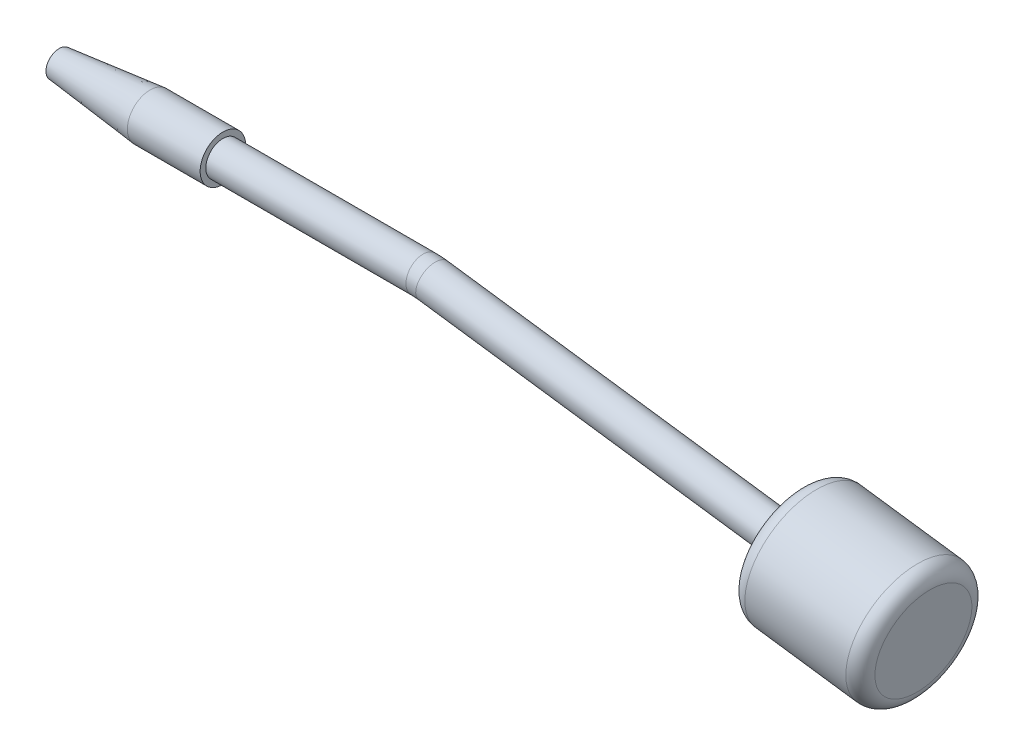
from build123d import *

# Parameters (mm, degrees)
SWEEP1_PROFILE_R = 2.9845
FILLET1_R        = 2.54


with BuildPart() as part:
    # Sketch1 → Revolve1 (revolve)
    with BuildSketch(Plane.XY):
        Polygon((-63.5, -0.79375), (-63.5, -2.286), (-47.625, -3.96875), (-34.925, -3.96875), (-34.925, -2.9845), (0, -2.9845), (0, -0.79375), align=None)
    revolve(axis=Axis((0, 0, 0), (-1, 0, 0)))

    # Sweep1: sweep along a path in Sketch2
    with BuildLine(Plane.XY) as sweep1_path:
        Line((64.63607564, -8.735441276), (1.72358777, -0.117502426))
        ThreePointArc((1.72358777, -0.117502426), (0.863794191, -0.029409659), (0, 0))
    # Sweep1 profile (on start of the path) → Sweep1 (sweep)
    with BuildSketch(Plane(origin=(64.63607564, -8.735441276, 0), x_dir=(-0.135715572, -0.99074784, 0), z_dir=(-0.99074784, 0.135715572, 0))):
        Circle(SWEEP1_PROFILE_R)
    sweep(path=sweep1_path.line)

    # Sketch15 → Revolve2 (revolve)
    with BuildSketch(Plane.XY):
        Polygon((87.284571273, -11.837899261), (85.802285791, -22.658847175), (63.153790158, -19.556389189), (64.63607564, -8.735441276), align=None)
    revolve(axis=Axis((64.63607564, -8.735441276, 0), (0.99074784, -0.135715572, 0)))

    # Fillet1
    fillet1_edges = [part.edges().sort_by_distance(p)[0] for p in [
        (88.766856755, -1.016951348, 0),
        (66.118361122, 2.085506638, 0),
    ]]
    fillet(fillet1_edges, radius=FILLET1_R)


solid = part.part
